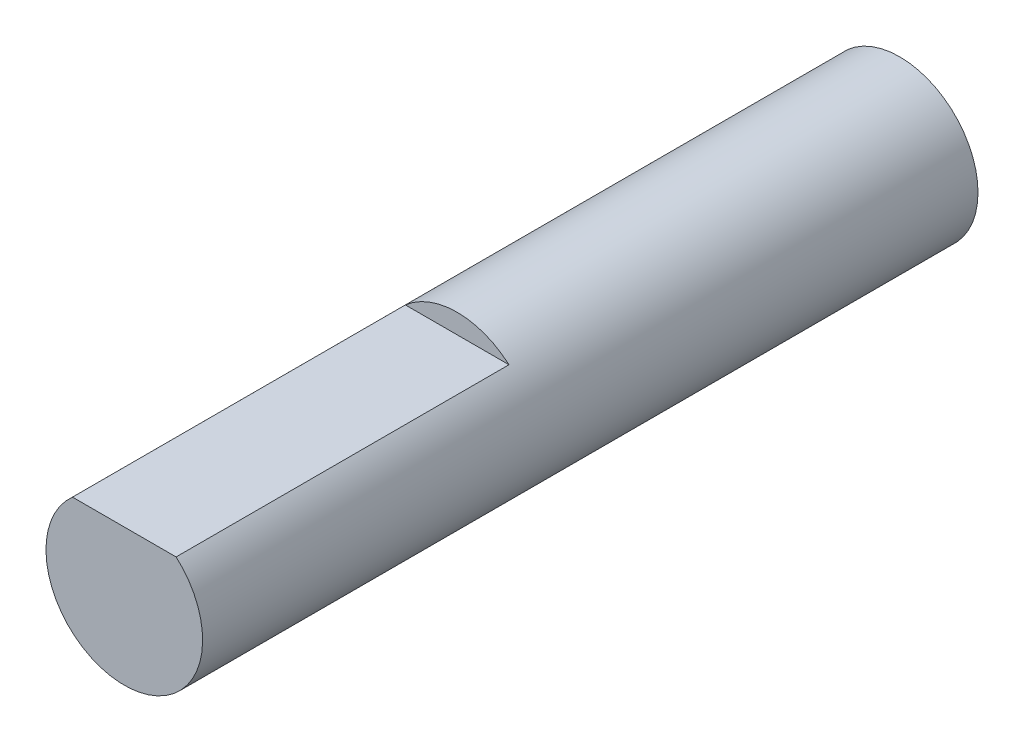
from build123d import *

# Parameters (mm, degrees)
SKETCH1_R               = 2
BOSS_EXTRUDE1_DEPTH     = 19.8
CUT_EXTRUDE1_DEPTH      = 1
CUT_EXTRUDE1_DEPTH_BACK = 8.5


with BuildPart() as part:
    # Sketch1 → Boss-Extrude1 (new body)
    with BuildSketch(Plane.XY):
        Circle(SKETCH1_R)
    extrude(amount=BOSS_EXTRUDE1_DEPTH)

    # Sketch2 → Cut-Extrude1 (cut, two sides)
    with BuildSketch(Plane.XY.offset(19.8)) as cut_extrude1_sk:
        Polygon((-20.975129822, 1.5), (-1.322875656, 1.5), (1.322875656, 1.5), (20.975129822, 1.5), (20.975129822, 40.804508332), (-20.975129822, 40.804508332), align=None)
    extrude(amount=CUT_EXTRUDE1_DEPTH, mode=Mode.SUBTRACT)
    extrude(cut_extrude1_sk.sketch, amount=-CUT_EXTRUDE1_DEPTH_BACK, mode=Mode.SUBTRACT)


solid = part.part
